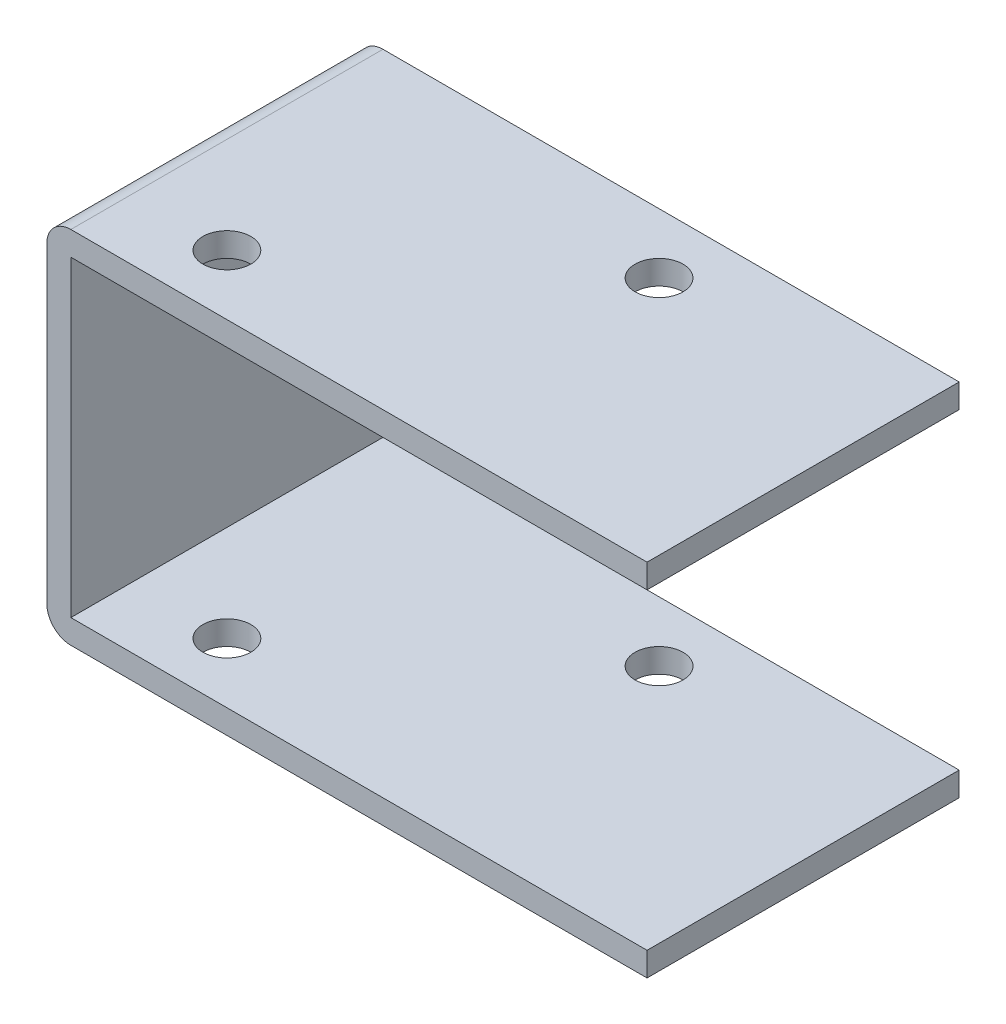
from build123d import *

# Parameters (mm, degrees)
BOSS_EXTRUDE1_DEPTH     = 13
CUT_EXTRUDE1_DEPTH      = 32.921779399
CUT_EXTRUDE1_DEPTH_BACK = 32.921779399
SKETCH3_R               = 1
CUT_EXTRUDE2_DEPTH      = 32.921779399
CUT_EXTRUDE2_DEPTH_BACK = 32.921779399
SKETCH3_4_R             = 1


with BuildPart() as part:
    # Sketch2 → Boss-Extrude1 (new body)
    with BuildSketch(Plane.XY):
        with BuildLine():
            Line((0, -1), (0, 0))
            Line((0, 0), (-24, 0))
            ThreePointArc((-24, 0), (-24.707106781, -0.292893219), (-25, -1))
            Line((-25, -1), (-25, -14))
            ThreePointArc((-25, -14), (-24.707106781, -14.707106781), (-24, -15))
            Line((-24, -15), (0, -15))
            Line((0, -15), (0, -14))
            Line((0, -14), (-24, -14))
            Line((-24, -14), (-24, -1))
            Line((-24, -1), (0, -1))
        make_face()
    extrude(amount=BOSS_EXTRUDE1_DEPTH)

    # Sketch3 → Cut-Extrude1 (cut, two sides: drawn at the far end of the back side and taken through both)
    with BuildSketch(Plane(origin=(0, 0, 0), x_dir=(1, 0, 0), z_dir=(0, 1, 0)).offset(-CUT_EXTRUDE1_DEPTH_BACK)):
        with Locations((-10, -2.5)):
            Circle(SKETCH3_R)
    extrude(amount=CUT_EXTRUDE1_DEPTH + CUT_EXTRUDE1_DEPTH_BACK, mode=Mode.SUBTRACT)

    # Sketch3_4 → Cut-Extrude2 (cut, two sides: drawn at the far end of the back side and taken through both)
    with BuildSketch(Plane(origin=(0, 0, 0), x_dir=(1, 0, 0), z_dir=(0, 1, 0)).offset(-CUT_EXTRUDE2_DEPTH_BACK)):
        with Locations((-10, -2.5)):
            Circle(SKETCH3_4_R)
        with Locations((-20, -10.5)):
            Circle(SKETCH3_4_R)
    extrude(amount=CUT_EXTRUDE2_DEPTH + CUT_EXTRUDE2_DEPTH_BACK, mode=Mode.SUBTRACT)


solid = part.part
